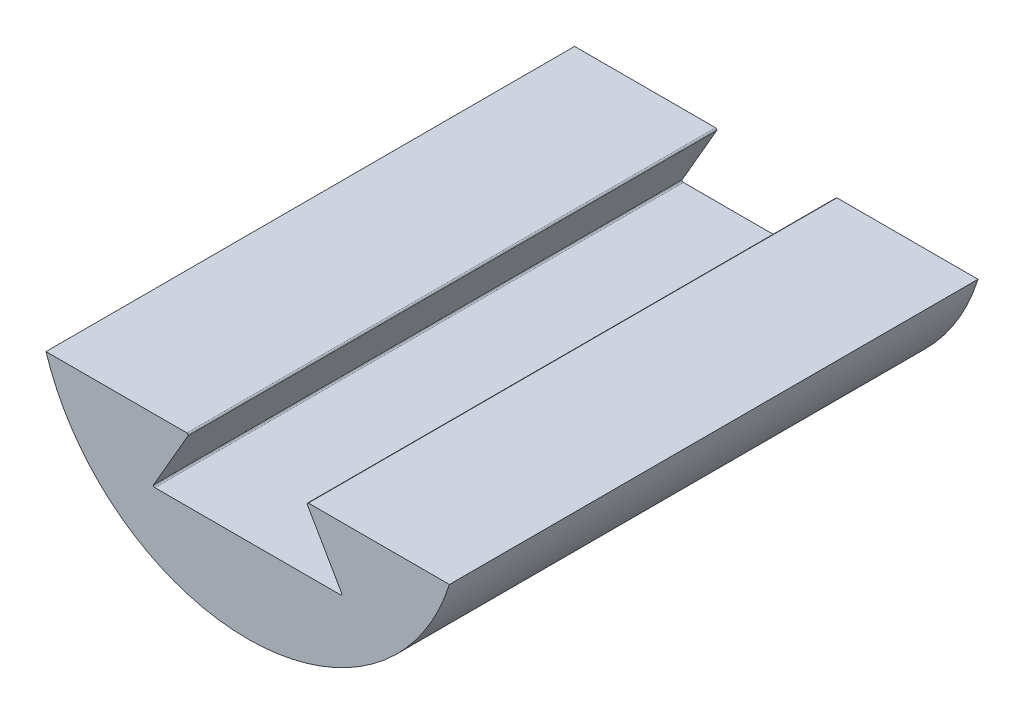
from build123d import *

# Parameters (mm, degrees)
BOSS_EXTRUDE1_DEPTH = 100
CUT_EXTRUDE1_DEPTH  = 101
FILLET1_R           = 0.25


with BuildPart() as part:
    # Sketch2 → Boss-Extrude1 (new body)
    with BuildSketch(Plane.XY):
        with BuildLine():
            Line((-38.157568057, -12), (38.157568057, -12))
            ThreePointArc((38.157568057, -12), (0, -40), (-38.157568057, -12))
        make_face()
    extrude(amount=BOSS_EXTRUDE1_DEPTH)

    # Sketch3 → Cut-Extrude1 (cut, through all)
    with BuildSketch(Plane(origin=(0, 0, 0), x_dir=(-1, 0, 0), z_dir=(0, 0, -1))):
        Polygon((-11.07179677, -12), (-18, -24), (18, -24), (11.07179677, -12), align=None)
    extrude(amount=-CUT_EXTRUDE1_DEPTH, mode=Mode.SUBTRACT)

    # Fillet1
    fillet1_edges = [part.edges().sort_by_distance(p)[0] for p in [
        (11.07179677, -12, 50),
        (-11.07179677, -12, 50),
        (-18, -24, 50),
        (18, -24, 50),
    ]]
    fillet(fillet1_edges, radius=FILLET1_R)


solid = part.part
